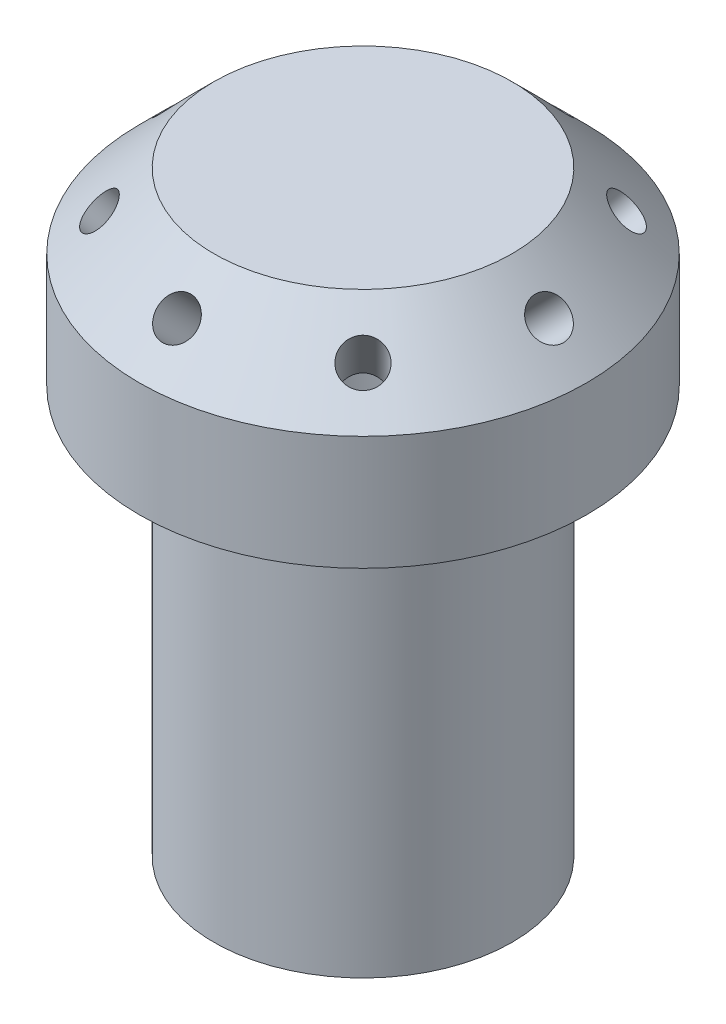
from build123d import *

# Parameters (mm, degrees)
SKETCH2_R          = 2.54
CUT_EXTRUDE1_DEPTH = 20.552143
CIRPATTERN1_COUNT  = 8


with BuildPart() as part:
    # Sketch1 → Revolve1 (revolve)
    with BuildSketch(Plane.XY):
        with BuildLine():
            Line((0, 76.2), (19.05, 76.2))
            Line((19.05, 76.2), (28.575, 66.675))
            Line((28.575, 66.675), (28.575, 52.07))
            Line((28.575, 52.07), (19.05, 52.07))
            Line((19.05, 52.07), (19.05, 0))
            Line((19.05, 0), (12.7, 0))
            Line((12.7, 0), (12.7, 48.895))
            ThreePointArc((12.7, 48.895), (8.980256121, 57.875256121), (0, 61.595))
            Line((0, 61.595), (0, 76.2))
        make_face()
    revolve(axis=Axis((0, 0, 0), (0, 1, 0)))

    # Sketch2 → Cut-Extrude1 (cut)
    with BuildSketch(Plane(origin=(47.625, 47.625, 0), x_dir=(0, 0, 1), z_dir=(-0.707106781, -0.707106781, 0))):
        with Locations((0, 33.675960454)):
            Circle(SKETCH2_R)
    cut_extrude1 = extrude(amount=CUT_EXTRUDE1_DEPTH, mode=Mode.SUBTRACT)

    # CirPattern1: Cut-Extrude1 ×8 about axis
    cirpattern1_axis = Axis((0, 0, 0), (0, -1, 0))
    for i in range(1, CIRPATTERN1_COUNT):
        add(cut_extrude1.rotate(cirpattern1_axis, i * 360 / CIRPATTERN1_COUNT), mode=Mode.SUBTRACT)


solid = part.part
